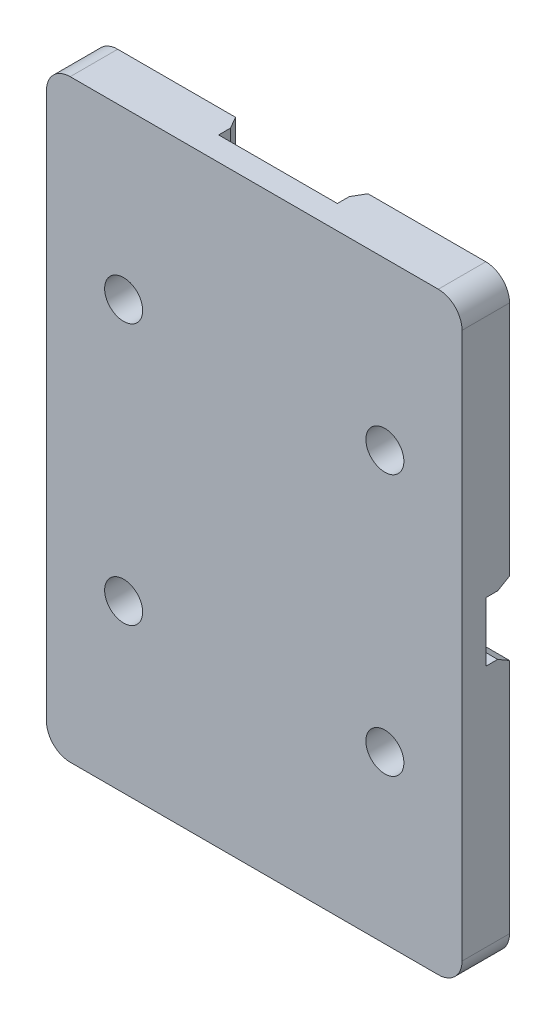
from build123d import *
from OCP.BRepFilletAPI import BRepFilletAPI_MakeChamfer

# Parameters (mm, degrees)
SCHIZZO1_W                   = 35
SCHIZZO1_H                   = 50
ESTRUSIONE_ESTRUSIONE1_DEPTH = 2
TAGLIO_ESTRUSIONE1_DEPTH     = 2
RACCORDO1_R                  = 2
SMUSSO1_SIZE                 = 1
SMUSSO1_SIZE2                = 0.577350269
SKETCH1_R                    = 1.6
CUT_EXTRUDE1_DEPTH           = 31.777426793
CUT_EXTRUDE1_DEPTH_BACK      = 31.777426793


with BuildPart() as part:
    # Schizzo1 → Estrusione-Estrusione1 (new, symmetric)
    with BuildSketch(Plane.XY):
        Rectangle(SCHIZZO1_W, SCHIZZO1_H)
    extrude(amount=ESTRUSIONE_ESTRUSIONE1_DEPTH, both=True)

    # Schizzo2 → Taglio-Estrusione1 (cut)
    with BuildSketch(Plane(origin=(0, 0, -2), x_dir=(-1, 0, 0), z_dir=(0, 0, -1))):
        Polygon((-5, -25), (5, -25), (5, -2.5), (17.5, -2.5), (17.5, 2.5), (5, 2.5), (5, 25), (-5, 25), (-5, 2.5), (-17.5, 2.5), (-17.5, -2.5), (-5, -2.5), align=None)
    extrude(amount=-TAGLIO_ESTRUSIONE1_DEPTH, mode=Mode.SUBTRACT)

    # Raccordo1
    raccordo1_edges = [part.edges().sort_by_distance(p)[0] for p in [
        (-5, 2.5, -1),
        (-5, -2.5, -1),
        (5, -2.5, -1),
        (5, 2.5, -1),
        (-17.5, -25, 0),
        (17.5, -25, 0),
        (17.5, 25, 0),
        (-17.5, 25, 0),
    ]]
    fillet(raccordo1_edges, radius=RACCORDO1_R)

    # Smusso1: one chamfer whose edges measure the first distance from different faces: ONE call of the kernel's chamfer builder (chamfer() names one face for all edges)
    smusso1_edges_1 = [part.edges().sort_by_distance(p)[0] for p in [
        (5, 14.75, -2),
    ]]
    smusso1_side_1 = [part.faces().sort_by_distance(p)[0] for p in [
        (5, 14.75, -1),
    ]]
    smusso1_edges_2 = [part.edges().sort_by_distance(p)[0] for p in [
        (12.25, -2.5, -2),
    ]]
    smusso1_side_2 = [part.faces().sort_by_distance(p)[0] for p in [
        (12.25, -2.5, -1),
    ]]
    smusso1_edges_3 = [part.edges().sort_by_distance(p)[0] for p in [
        (-5, -14.75, -2),
    ]]
    smusso1_side_3 = [part.faces().sort_by_distance(p)[0] for p in [
        (-5, -14.75, -1),
    ]]
    smusso1_edges_4 = [part.edges().sort_by_distance(p)[0] for p in [
        (-12.25, 2.5, -2),
    ]]
    smusso1_side_4 = [part.faces().sort_by_distance(p)[0] for p in [
        (-12.25, 2.5, -1),
    ]]
    smusso1_edges_5 = [part.edges().sort_by_distance(p)[0] for p in [
        (5, -14.75, -2),
    ]]
    smusso1_side_5 = [part.faces().sort_by_distance(p)[0] for p in [
        (5, -14.75, -1),
    ]]
    smusso1_edges_6 = [part.edges().sort_by_distance(p)[0] for p in [
        (5.585786438, -3.085786438, -2),
    ]]
    smusso1_side_6 = [part.faces().sort_by_distance(p)[0] for p in [
        (5.585786438, -3.085786438, -1),
    ]]
    smusso1_edges_7 = [part.edges().sort_by_distance(p)[0] for p in [
        (-5, 14.75, -2),
    ]]
    smusso1_side_7 = [part.faces().sort_by_distance(p)[0] for p in [
        (-5, 14.75, -1),
    ]]
    smusso1_edges_8 = [part.edges().sort_by_distance(p)[0] for p in [
        (-5.585786438, 3.085786438, -2),
    ]]
    smusso1_side_8 = [part.faces().sort_by_distance(p)[0] for p in [
        (-5.585786438, 3.085786438, -1),
    ]]
    smusso1_edges_9 = [part.edges().sort_by_distance(p)[0] for p in [
        (-12.25, -2.5, -2),
    ]]
    smusso1_side_9 = [part.faces().sort_by_distance(p)[0] for p in [
        (-12.25, -2.5, -1),
    ]]
    smusso1_edges_10 = [part.edges().sort_by_distance(p)[0] for p in [
        (-5.585786438, -3.085786438, -2),
    ]]
    smusso1_side_10 = [part.faces().sort_by_distance(p)[0] for p in [
        (-5.585786438, -3.085786438, -1),
    ]]
    smusso1_edges_11 = [part.edges().sort_by_distance(p)[0] for p in [
        (12.25, 2.5, -2),
    ]]
    smusso1_side_11 = [part.faces().sort_by_distance(p)[0] for p in [
        (12.25, 2.5, -1),
    ]]
    smusso1_edges_12 = [part.edges().sort_by_distance(p)[0] for p in [
        (5.585786438, 3.085786438, -2),
    ]]
    smusso1_side_12 = [part.faces().sort_by_distance(p)[0] for p in [
        (5.585786438, 3.085786438, -1),
    ]]
    smusso1 = BRepFilletAPI_MakeChamfer(part.part.solid().wrapped)
    for e in smusso1_edges_1:
        smusso1.Add(SMUSSO1_SIZE, SMUSSO1_SIZE2, e.wrapped, smusso1_side_1[0].wrapped)  # the first distance lies on this face
    for e in smusso1_edges_2:
        smusso1.Add(SMUSSO1_SIZE, SMUSSO1_SIZE2, e.wrapped, smusso1_side_2[0].wrapped)  # the first distance lies on this face
    for e in smusso1_edges_3:
        smusso1.Add(SMUSSO1_SIZE, SMUSSO1_SIZE2, e.wrapped, smusso1_side_3[0].wrapped)  # the first distance lies on this face
    for e in smusso1_edges_4:
        smusso1.Add(SMUSSO1_SIZE, SMUSSO1_SIZE2, e.wrapped, smusso1_side_4[0].wrapped)  # the first distance lies on this face
    for e in smusso1_edges_5:
        smusso1.Add(SMUSSO1_SIZE, SMUSSO1_SIZE2, e.wrapped, smusso1_side_5[0].wrapped)  # the first distance lies on this face
    for e in smusso1_edges_6:
        smusso1.Add(SMUSSO1_SIZE, SMUSSO1_SIZE2, e.wrapped, smusso1_side_6[0].wrapped)  # the first distance lies on this face
    for e in smusso1_edges_7:
        smusso1.Add(SMUSSO1_SIZE, SMUSSO1_SIZE2, e.wrapped, smusso1_side_7[0].wrapped)  # the first distance lies on this face
    for e in smusso1_edges_8:
        smusso1.Add(SMUSSO1_SIZE, SMUSSO1_SIZE2, e.wrapped, smusso1_side_8[0].wrapped)  # the first distance lies on this face
    for e in smusso1_edges_9:
        smusso1.Add(SMUSSO1_SIZE, SMUSSO1_SIZE2, e.wrapped, smusso1_side_9[0].wrapped)  # the first distance lies on this face
    for e in smusso1_edges_10:
        smusso1.Add(SMUSSO1_SIZE, SMUSSO1_SIZE2, e.wrapped, smusso1_side_10[0].wrapped)  # the first distance lies on this face
    for e in smusso1_edges_11:
        smusso1.Add(SMUSSO1_SIZE, SMUSSO1_SIZE2, e.wrapped, smusso1_side_11[0].wrapped)  # the first distance lies on this face
    for e in smusso1_edges_12:
        smusso1.Add(SMUSSO1_SIZE, SMUSSO1_SIZE2, e.wrapped, smusso1_side_12[0].wrapped)  # the first distance lies on this face
    add(Compound.cast(smusso1.Shape()), mode=Mode.REPLACE)

    # Sketch1 → Cut-Extrude1 (cut, two sides)
    with BuildSketch(Plane.XY.offset(2)) as cut_extrude1_sk:
        with Locations((-11, 11)):
            Circle(SKETCH1_R)
        with Locations(Location((11, 11, 0), (0, 0, 180))):
            Circle(SKETCH1_R)
        with Locations((11, -11)):
            Circle(SKETCH1_R)
        with Locations(Location((-11, -11, 0), (0, 0, 180))):
            Circle(SKETCH1_R)
    extrude(amount=CUT_EXTRUDE1_DEPTH, mode=Mode.SUBTRACT)
    extrude(cut_extrude1_sk.sketch, amount=-CUT_EXTRUDE1_DEPTH_BACK, mode=Mode.SUBTRACT)


solid = part.part
